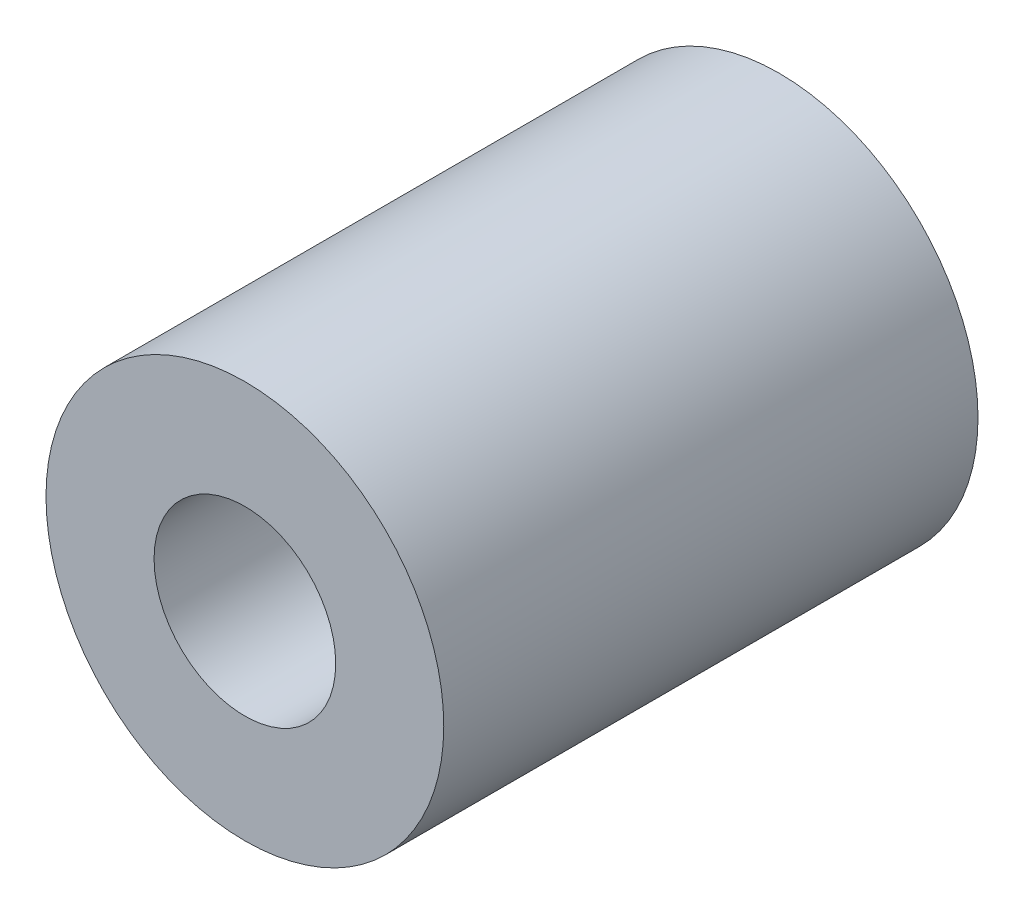
from build123d import *

# Parameters (mm, degrees)
SKETCH1_R           = 5.584000144
BOSS_EXTRUDE1_DEPTH = 15
SKETCH2_R           = 2.6
CUT_EXTRUDE1_DEPTH  = 8.2
SKETCH3_R           = 2.55
CUT_EXTRUDE2_DEPTH  = 7


with BuildPart() as part:
    # Sketch1 → Boss-Extrude1 (new body)
    with BuildSketch(Plane.XY):
        with Locations((-60.533127818, -24.469533588)):
            Circle(SKETCH1_R)
    extrude(amount=BOSS_EXTRUDE1_DEPTH)

    # Sketch2 → Cut-Extrude1 (cut)
    with BuildSketch(Plane(origin=(0, 0, 0), x_dir=(-1, 0, 0), z_dir=(0, 0, -1))):
        with Locations((60.533127818, -24.469533588)):
            Circle(SKETCH2_R)
    extrude(amount=-CUT_EXTRUDE1_DEPTH, mode=Mode.SUBTRACT)

    # Sketch3 → Cut-Extrude2 (cut)
    with BuildSketch(Plane.XY.offset(15)):
        with Locations((-60.533127818, -24.469533588)):
            Circle(SKETCH3_R)
    extrude(amount=-CUT_EXTRUDE2_DEPTH, mode=Mode.SUBTRACT)


solid = part.part
